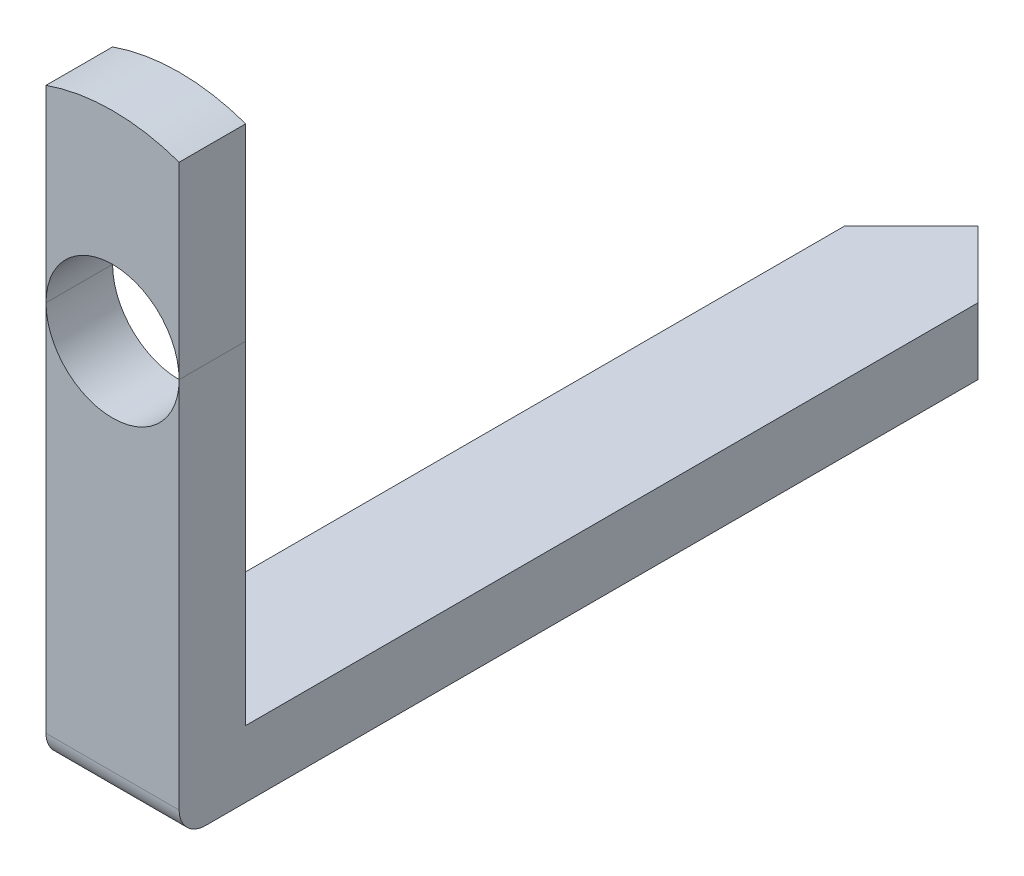
from build123d import *

# Parameters (mm, degrees)
ESQUISSE1_R             = 0.5
BOSS_EXTRU_1_DEPTH      = 0.5
BOSS_EXTRU_2_DEPTH      = 0.5
CONG_1_R                = 0.2
ENL_V_MAT_EXTRU_1_DEPTH = 5.5


with BuildPart() as part:
    # Esquisse1 → Boss.-Extru.1 (new body)
    with BuildSketch(Plane.XY):
        with BuildLine():
            Line((-1.5, 0), (-1.5, -3))
            Line((-1.5, -3), (1.5, -3))
            Line((1.5, -3), (1.5, 0))
            ThreePointArc((1.5, 0), (0, 1.5), (-1.5, 0))
        make_face()
        Circle(ESQUISSE1_R, mode=Mode.SUBTRACT)
    extrude(amount=BOSS_EXTRU_1_DEPTH)

    # Esquisse2 → Boss.-Extru.2 (add)
    with BuildSketch(Plane.XZ.offset(3)):
        Polygon((-1.5, 0.5), (1.5, 0.5), (1.5, -1), (0.5, -1), (0.5, -5.5), (0, -6), (-0.5, -5.5), (-0.5, -1), (-1.5, -1), align=None)
    extrude(amount=-BOSS_EXTRU_2_DEPTH)

    # Congé1
    cong_1_edges = [part.edges().sort_by_distance(p)[0] for p in [
        (0, -3, 0.5),
    ]]
    fillet(cong_1_edges, radius=CONG_1_R)

    # Esquisse3 → Enlèv. mat.-Extru.1 (cut, through all)
    with BuildSketch(Plane.XZ.offset(3)):
        Polygon((-0.5, -1.249868896), (-2.524344938, -1.249868896), (-2.524344938, 1.009826976), (0.183218584, 1.416979386), (1.913616324, 1.009826976), (1.913616324, -1.249868896), (0.5, -1.249868896), (0.5, 1.009826976), (-0.5, 1.009826976), align=None)
    extrude(amount=-ENL_V_MAT_EXTRU_1_DEPTH, mode=Mode.SUBTRACT)


solid = part.part
